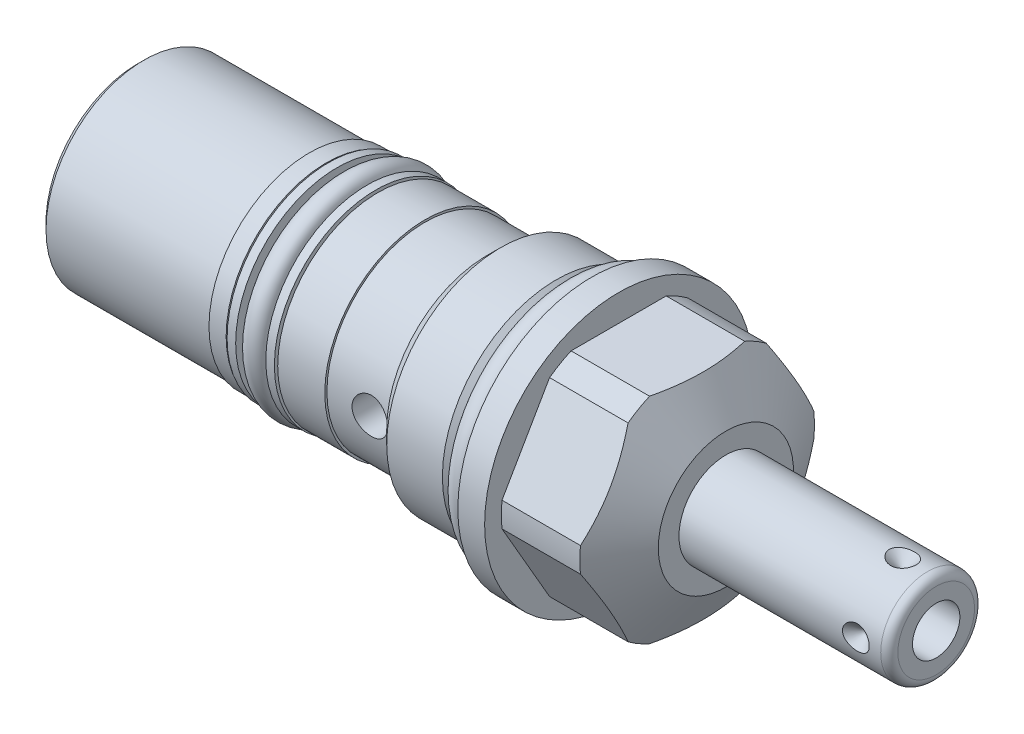
from build123d import *

# Parameters (mm, degrees)
SKETCH1_R           = 15.875
EXTRUDE1_DEPTH      = 15.875
EXTRUDE1_DEPTH_BACK = 53.7972
CUT_EXTRUDE1_REACH  = 55.797
SKETCH2_R           = 15.875
SKETCH2_R_2         = 13.49375
CUT_EXTRUDE3_REACH  = 14.7
SKETCH5_R           = 15.875
CUT_EXTRUDE5_REACH  = 14.7
SKETCH7_R           = 15.875
SKETCH7_R_2         = 13.8938
SKETCH12_W          = 6.1087
SKETCH12_H          = 2.0447
SKETCH14_W          = 0.254
SKETCH14_H          = 20.32
SKETCH14_H_2        = 7.3406
SKETCH15_R          = 1.4732
SKETCH16_W          = 2.1844
SKETCH16_H          = 1.016
SKETCH17_R          = 1.3081
CIRPATTERN1_COUNT   = 4
CHAMFER1_SIZE       = 0.762
SKETCH22_R          = 0.8001
CUT_EXTRUDE6_DEPTH  = 0.762
SKETCH23_R          = 2.1082
CUT_EXTRUDE7_DEPTH  = 16.875


with BuildPart() as part:
    # Sketch1 → Extrude1 (new body, two sides)
    with BuildSketch(Plane(origin=(0, 0, 0), x_dir=(0, 0, -1), z_dir=(1, 0, 0))) as extrude1_sk:
        Circle(SKETCH1_R)
    extrude(amount=EXTRUDE1_DEPTH)
    extrude(extrude1_sk.sketch, amount=-EXTRUDE1_DEPTH_BACK)

    # Sketch2 → Cut-Extrude1 (cut, up to next)
    with BuildSketch(Plane(origin=(0, 0, 0), x_dir=(0, 0, -1), z_dir=(1, 0, 0)), mode=Mode.PRIVATE) as cut_extrude1_sk1:
        Circle(SKETCH2_R)
        Circle(SKETCH2_R_2, mode=Mode.SUBTRACT)
    cut_extrude1_tool1 = extrude(cut_extrude1_sk1.sketch, amount=-CUT_EXTRUDE1_REACH, mode=Mode.PRIVATE) & part.part
    add(cut_extrude1_tool1.solids().sort_by_distance((0, 0, 15.425987))[0], mode=Mode.SUBTRACT)

    # Sketch3 → Cut-Revolve1 (revolve, cut)
    with BuildSketch(Plane.XY, mode=Mode.PRIVATE) as cut_revolve1_sk:
        Polygon((11.32894398, 15.875), (15.875, 8.001), (15.875, 15.875), align=None)
    revolve(cut_revolve1_sk.sketch.rotate(Axis((-8.14577342, 0, 0), (1, 0, 0)), 270), axis=Axis((-8.14577342, 0, 0), (1, 0, 0)), mode=Mode.SUBTRACT)  # turned: the seam where the file's is

    # Cut-Extrude3: up to this cone (the profile starts inside it)
    cut_extrude3_end = Plane(origin=(3.175, 0, 0), z_dir=(-1, 0, 0)).offset(-17.319378504) * Cone(1.732e-06, 108.283356043, 62.51742376, align=(Align.CENTER, Align.CENTER, Align.MIN), mode=Mode.PRIVATE)
    # Sketch5 → Cut-Extrude3 (cut, up to the surface)
    with BuildSketch(Plane.ZY.offset(-3.175), mode=Mode.PRIVATE) as cut_extrude3_sk1:
        with Locations(Location((0, 0, 0), (0, 0, 180))):  # turned: the seam where the file's is
            Circle(SKETCH5_R)
        Polygon((-7.332348419, 12.7), (7.332348419, 12.7), (14.664696837, 0), (7.332348419, -12.7), (-7.332348419, -12.7), (-14.664696837, 0), align=None, mode=Mode.SUBTRACT)
    cut_extrude3_tool1 = extrude(cut_extrude3_sk1.sketch, amount=-CUT_EXTRUDE3_REACH, mode=Mode.PRIVATE) & cut_extrude3_end
    add(cut_extrude3_tool1.solids().sort_by_distance((3.175, 0, 15.425987))[0], mode=Mode.SUBTRACT)

    # Cut-Extrude5: up to this cone (the profile starts inside it)
    cut_extrude5_end = Plane(origin=(3.175, 0, 0), z_dir=(-1, 0, 0)).offset(-17.319378504) * Cone(1.732e-06, 108.283356043, 62.51742376, align=(Align.CENTER, Align.CENTER, Align.MIN), mode=Mode.PRIVATE)
    # Sketch7 → Cut-Extrude5 (cut, up to the surface)
    with BuildSketch(Plane.ZY.offset(-3.175), mode=Mode.PRIVATE) as cut_extrude5_sk1:
        with Locations(Location((0, 0, 0), (0, 0, 180))):  # turned: the seam where the file's is
            Circle(SKETCH7_R)
        Circle(SKETCH7_R_2, mode=Mode.SUBTRACT)
    cut_extrude5_tool1 = extrude(cut_extrude5_sk1.sketch, amount=-CUT_EXTRUDE5_REACH, mode=Mode.PRIVATE) & cut_extrude5_end
    add(cut_extrude5_tool1.solids().sort_by_distance((3.175, 0, 15.425987))[0], mode=Mode.SUBTRACT)

    # Sketch9 → Cut-Revolve3 (revolve, cut)
    with BuildSketch(Plane.XY, mode=Mode.PRIVATE) as cut_revolve3_sk:
        Polygon((0, 13.49375), (0, 12.0015), (-2.7178, 12.0015), (-4.21005, 13.49375), align=None)
    revolve(cut_revolve3_sk.sketch.rotate(Axis((-4.4205525, 0, 0), (1, 0, 0)), 90), axis=Axis((-4.4205525, 0, 0), (1, 0, 0)), mode=Mode.SUBTRACT)  # turned: the seam where the file's is

    # Sketch10 → Cut-Revolve4 (revolve, cut)
    with BuildSketch(Plane.XY, mode=Mode.PRIVATE) as cut_revolve4_sk:
        Polygon((-10.80135, 13.49375), (-12.4206, 11.8745), (-53.7972, 11.8745), (-53.7972, 13.49375), align=None)
    revolve(cut_revolve4_sk.sketch.rotate(Axis((-55.9469925, 0, 0), (1, 0, 0)), 90), axis=Axis((-55.9469925, 0, 0), (1, 0, 0)), mode=Mode.SUBTRACT)  # turned: the seam where the file's is

    # Sketch12 → Cut-Revolve6 (revolve, cut)
    with BuildSketch(Plane.XY, mode=Mode.PRIVATE) as cut_revolve6_sk:
        with Locations((-28.39085, 10.85215)):
            Rectangle(SKETCH12_W, SKETCH12_H)
    revolve(cut_revolve6_sk.sketch.rotate(Axis((-31.750635, 0, 0), (1, 0, 0)), 90), axis=Axis((-31.750635, 0, 0), (1, 0, 0)), mode=Mode.SUBTRACT)  # turned: the seam where the file's is

    # Sketch14 → Cut-Revolve8 (revolve, cut)
    with BuildSketch(Plane(origin=(0, 0, 0), x_dir=(0, -1, 0), z_dir=(0, 0, 1)), mode=Mode.PRIVATE) as cut_revolve8_sk:
        with Locations((11.7475, -43.6372)):
            Rectangle(SKETCH14_W, SKETCH14_H)
        with Locations((11.7475, -16.0909)):
            Rectangle(SKETCH14_W, SKETCH14_H_2)
    revolve(cut_revolve8_sk.sketch.rotate(Axis((-55.86603, 0, 0), (1, 0, 0)), 270), axis=Axis((-55.86603, 0, 0), (1, 0, 0)), mode=Mode.SUBTRACT)  # turned: the seam where the file's is

    # Sketch16 → Revolve2 (revolve)
    with BuildSketch(Plane(origin=(0, 0, 0), x_dir=(0, -1, 0), z_dir=(0, 0, 1)), mode=Mode.PRIVATE) as revolve2_sk:
        with Locations((10.922, -26.0985)):
            Rectangle(SKETCH16_W, SKETCH16_H)
        with Locations((10.922, -30.6832)):
            Rectangle(SKETCH16_W, SKETCH16_H)
    revolve(revolve2_sk.sketch.rotate(Axis((-31.471235, 0, 0), (1, 0, 0)), 270), axis=Axis((-31.471235, 0, 0), (1, 0, 0)))  # turned: the seam where the file's is

    # S2D0001 → Revolve4 (revolve)
    with BuildSketch(Plane(origin=(0, 0, 0), x_dir=(0, -1, 0), z_dir=(0, 0, 1)), mode=Mode.PRIVATE) as revolve4_sk:
        with BuildLine():
            Line((0, 15.875), (-5.55625, 15.875))
            Line((-5.55625, 15.875), (-5.55625, 39.7764))
            ThreePointArc((-5.55625, 39.7764), (-5.25867049, 40.49482049), (-4.54025, 40.7924))
            Line((-4.54025, 40.7924), (0, 40.7924))
            Line((0, 40.7924), (0, 15.875))
        make_face()
    revolve(revolve4_sk.sketch.rotate(Axis((7.265766347, 0, 0), (1, 0, 0)), 90), axis=Axis((7.265766347, 0, 0), (1, 0, 0)))  # turned: the seam where the file's is

    # Sketch19 → Cut-Revolve9 (revolve, cut)
    with BuildSketch(Plane(origin=(36.322, -2.8067, 0), x_dir=(0, -1, 0), z_dir=(0, 0, 1)), mode=Mode.PRIVATE) as cut_revolve9_sk:
        Polygon((0, 4.4704), (0, -5.6896), (-2.8067, -7.376035499), (-2.8067, 4.4704), align=None)
    revolve(cut_revolve9_sk.sketch.rotate(Axis((17.699325537, 0, 0), (1, 0, 0)), 270), axis=Axis((17.699325537, 0, 0), (1, 0, 0)), mode=Mode.SUBTRACT)  # turned: the seam where the file's is

    # S2D0002 → Cut-Revolve10 (revolve, cut)
    with BuildSketch(Plane(origin=(32.3596, 0, -5.55625), x_dir=(1, 0, 0), z_dir=(0, 1, 0)), mode=Mode.PRIVATE) as cut_revolve10_sk:
        Polygon((4.4704, 0), (6.0579, 0), (4.4704, -1.5875), align=None)
    cut_revolve10 = revolve(cut_revolve10_sk.sketch.rotate(Axis((36.83, 0, -2.191027232), (0, 0, -1)), 180), axis=Axis((36.83, 0, -2.191027232), (0, 0, -1)), mode=Mode.SUBTRACT)  # turned: the seam where the file's is

    # CirPattern1: Cut-Revolve10 ×4 about axis
    cirpattern1_axis = Axis((7.265766347, 0, 0), (-1, 0, 0))
    for i in range(1, CIRPATTERN1_COUNT):
        add(cut_revolve10.rotate(cirpattern1_axis, i * 360 / CIRPATTERN1_COUNT), mode=Mode.SUBTRACT)

    # Chamfer1
    chamfer1_edges = [part.edges().sort_by_distance(p)[0] for p in [
        (-53.7972, 0, -11.6205),
    ]]
    chamfer(chamfer1_edges, length=CHAMFER1_SIZE)

    # Sketch22 → Cut-Extrude6 (cut)
    with BuildSketch(Plane.ZY.offset(53.7972)):
        Circle(SKETCH22_R)
    extrude(amount=-CUT_EXTRUDE6_DEPTH, mode=Mode.SUBTRACT)

    # Sketch23 → Cut-Extrude7 (cut, through all)
    with BuildSketch(Plane.XY):
        with Locations((-14.6812, 0)):
            Circle(SKETCH23_R)
    extrude(amount=CUT_EXTRUDE7_DEPTH, mode=Mode.SUBTRACT)


with BuildPart() as body_2:
    # Sketch15 → Revolve1 (revolve)
    with BuildSketch(Plane(origin=(0, 0, 0), x_dir=(0, -1, 0), z_dir=(0, 0, 1)), mode=Mode.PRIVATE) as revolve1_sk:
        with Locations((13.4747, -1.4732)):
            Circle(SKETCH15_R)
    revolve(revolve1_sk.sketch.rotate(Axis((-3.09372, 0, 0), (1, 0, 0)), 270), axis=Axis((-3.09372, 0, 0), (1, 0, 0)))  # turned: the seam where the file's is


with BuildPart() as body_3:
    # Sketch17 → Revolve3 (revolve)
    with BuildSketch(Plane(origin=(0, 0, 0), x_dir=(0, -1, 0), z_dir=(0, 0, 1)), mode=Mode.PRIVATE) as revolve3_sk:
        with Locations((11.1379, -28.39085)):
            Circle(SKETCH17_R)
    revolve(revolve3_sk.sketch.rotate(Axis((-31.750635, 0, 0), (1, 0, 0)), 270), axis=Axis((-31.750635, 0, 0), (1, 0, 0)))  # turned: the seam where the file's is


solid = Compound([part.part, body_2.part, body_3.part])
